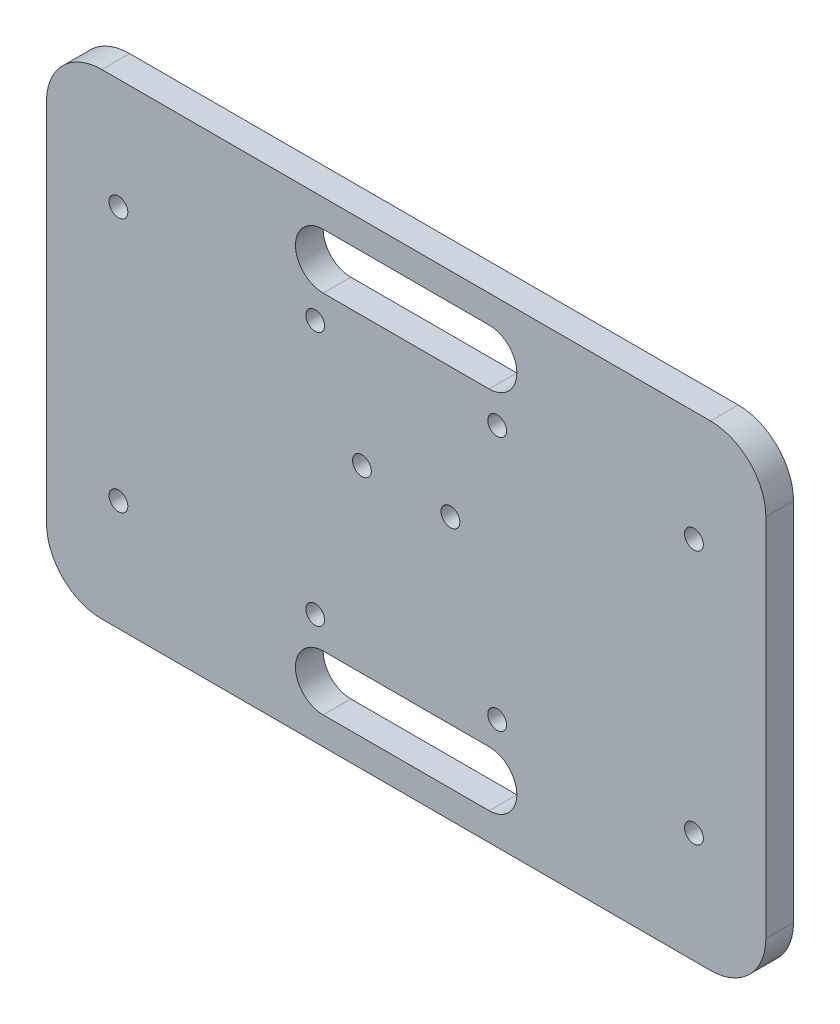
from build123d import *

# Parameters (mm, degrees)
SKETCH1_R           = 1.7
BOSS_EXTRUDE1_DEPTH = 5


with BuildPart() as part:
    # Sketch1 → Boss-Extrude1 (new body)
    with BuildSketch(Plane.XY):
        with BuildLine():
            ThreePointArc((-55, 43), (-62.071067812, 40.071067812), (-65, 33))
            Line((-65, 33), (-65, -33))
            ThreePointArc((-65, -33), (-62.071067812, -40.071067812), (-55, -43))
            Line((-55, -43), (55, -43))
            ThreePointArc((55, -43), (62.071067812, -40.071067812), (65, -33))
            Line((65, -33), (65, 33))
            ThreePointArc((65, 33), (62.071067812, 40.071067812), (55, 43))
            Line((55, 43), (-55, 43))
        make_face()
        with Locations((52, -23)):
            Circle(SKETCH1_R, mode=Mode.SUBTRACT)
        with Locations((-52, -23)):
            Circle(SKETCH1_R, mode=Mode.SUBTRACT)
        with Locations((52, 23)):
            Circle(SKETCH1_R, mode=Mode.SUBTRACT)
        with Locations((-52, 23)):
            Circle(SKETCH1_R, mode=Mode.SUBTRACT)
        with BuildLine():
            ThreePointArc((15, 38), (20, 33), (15, 28))
            Line((15, 28), (-15, 28))
            ThreePointArc((-15, 28), (-20, 33), (-15, 38))
            Line((-15, 38), (15, 38))
        make_face(mode=Mode.SUBTRACT)
        with Locations((-16.44, -23)):
            Circle(SKETCH1_R, mode=Mode.SUBTRACT)
        with BuildLine():
            ThreePointArc((-15, -38), (-20, -33), (-15, -28))
            Line((-15, -28), (15, -28))
            ThreePointArc((15, -28), (20, -33), (15, -38))
            Line((15, -38), (-15, -38))
        make_face(mode=Mode.SUBTRACT)
        with Locations((16.44, -23)):
            Circle(SKETCH1_R, mode=Mode.SUBTRACT)
        with Locations((-8, 4.5)):
            Circle(SKETCH1_R, mode=Mode.SUBTRACT)
        with Locations((-16.44, 23)):
            Circle(SKETCH1_R, mode=Mode.SUBTRACT)
        with Locations((8, 4.5)):
            Circle(SKETCH1_R, mode=Mode.SUBTRACT)
        with Locations((16.44, 23)):
            Circle(SKETCH1_R, mode=Mode.SUBTRACT)
    extrude(amount=BOSS_EXTRUDE1_DEPTH)


solid = part.part
